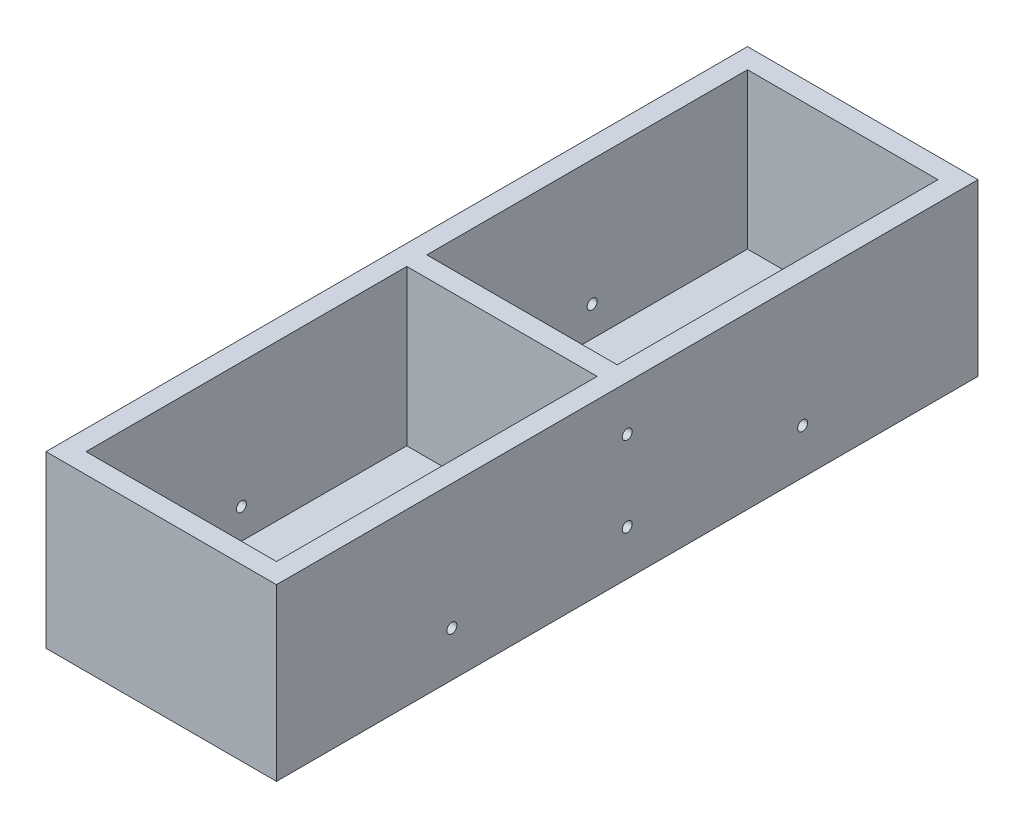
from build123d import *

# Parameters (mm, degrees)
BOSS_EXTRUDE1_DEPTH      = 70
SKETCH2_W                = 23
SKETCH2_H                = 17
BOSS_EXTRUDE2_DEPTH      = 2
SKETCH3_W                = 23
SKETCH3_H                = 17
BOSS_EXTRUDE3_DEPTH      = 2
SKETCH4_W                = 23
SKETCH4_H                = 17
BOSS_EXTRUDE4_DEPTH      = 1
BOSS_EXTRUDE4_DEPTH_BACK = 1
SKETCH6_R                = 0.5
CUT_EXTRUDE7_DEPTH       = 57
SKETCH7_R                = 0.5
CUT_EXTRUDE8_DEPTH       = 57


with BuildPart() as part:
    # Sketch1 → Boss-Extrude1 (new body)
    with BuildSketch(Plane.XY):
        Polygon((-11.5, 8.5), (-11.5, -8.5), (11.5, -8.5), (11.5, 8.5), (9.5, 8.5), (9.5, 7), (9.5, -7), (-9.5, -7), (-9.5, 7), (-9.5, 8.5), align=None)
    extrude(amount=BOSS_EXTRUDE1_DEPTH)

    # Sketch2 → Boss-Extrude2 (add)
    with BuildSketch(Plane.XY.offset(70)):
        Rectangle(SKETCH2_W, SKETCH2_H)
    extrude(amount=-BOSS_EXTRUDE2_DEPTH)

    # Sketch3 → Boss-Extrude3 (add)
    with BuildSketch(Plane(origin=(0, 0, 0), x_dir=(-1, 0, 0), z_dir=(0, 0, -1))):
        Rectangle(SKETCH3_W, SKETCH3_H)
    extrude(amount=-BOSS_EXTRUDE3_DEPTH)

    # Sketch4 → Boss-Extrude4 (add, two sides)
    with BuildSketch(Plane(origin=(0, 0, 35), x_dir=(-1, 0, 0), z_dir=(0, 0, -1))) as boss_extrude4_sk:
        Rectangle(SKETCH4_W, SKETCH4_H)
    extrude(amount=BOSS_EXTRUDE4_DEPTH)
    extrude(boss_extrude4_sk.sketch, amount=-BOSS_EXTRUDE4_DEPTH_BACK)

    # Sketch6 → Cut-Extrude7 (cut)
    with BuildSketch(Plane(origin=(11.5, 0, 0), x_dir=(0, 0, -1), z_dir=(1, 0, 0))):
        with Locations((-35, -4)):
            Circle(SKETCH6_R)
    cut_extrude7 = extrude(amount=-CUT_EXTRUDE7_DEPTH, mode=Mode.SUBTRACT)

    # Sketch7 → Cut-Extrude8 (cut)
    with BuildSketch(Plane(origin=(11.5, 0, 0), x_dir=(0, 0, -1), z_dir=(1, 0, 0))):
        with Locations((-52.5, -4)):
            Circle(SKETCH7_R)
    cut_extrude8 = extrude(amount=-CUT_EXTRUDE8_DEPTH, mode=Mode.SUBTRACT)

    # Mirror1: Cut-Extrude8 across plane
    add(cut_extrude8.mirror(Plane(origin=(0, 0, 35), x_dir=(1, 0, 0), z_dir=(0, 0, -1))), mode=Mode.SUBTRACT)

    # Mirror2: Cut-Extrude7 across plane
    add(cut_extrude7.mirror(Plane.ZX), mode=Mode.SUBTRACT)


solid = part.part
